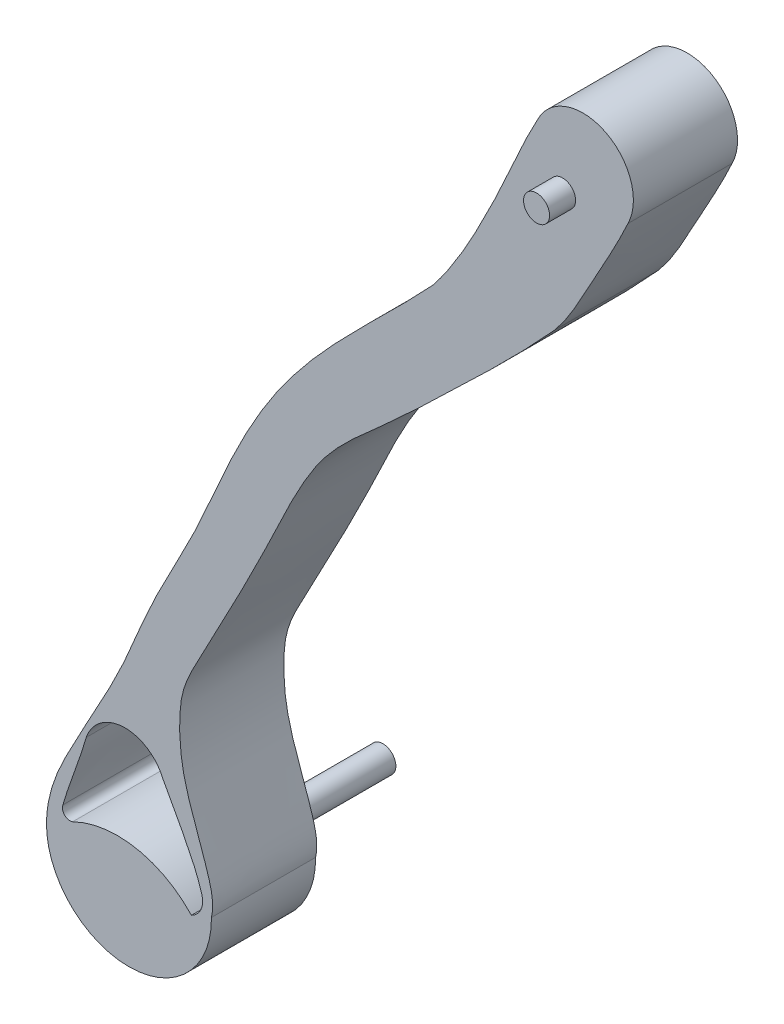
from build123d import *

# Parameters (mm, degrees)
BOSS_EXTRUDE1_DEPTH = 40
SKETCH3_R           = 5
BOSS_EXTRUDE3_DEPTH = 10
CUT_EXTRUDE1_DEPTH  = 40
BOSS_EXTRUDE6_START = -50
SKETCH3_2_R         = 5
BOSS_EXTRUDE6_DEPTH = 50
SKETCH4_R           = 5
BOSS_EXTRUDE7_DEPTH = 100


with BuildPart() as part:
    # Sketch1 → Boss-Extrude1 (new body)
    with BuildSketch(Plane.XY):
        with BuildLine():
            ThreePointArc((-128.435303347, -140.896902453), (-96.755149526, -173.125351057), (-65.074995705, -140.896902453))
            add(Edge.make_bspline(
                [(-65.074995705, -140.896902453), (-63.907652097, -135.87464552), (-66.35100912, -126.659238679), (-71.697657005, -112.128089654), (-76.334712316, -98.472209398), (-77.541709446, -84.207198732), (-76.961960819, -70.342092539), (-68.88579276, -55.69495944), (-58.213845257, -35.305524849), (-45.109839414, -10.285325139), (-33.851241856, 14.939291119), (-19.441261208, 38.761764832), (0.34611134, 54.846253057), (30.149690797, 83.353080433), (52.005250373, 104.155990976), (66.875865875, 120.550338304)],
                knots=[0, 0, 0, 0, 0.04686952, 0.090141713, 0.148581226, 0.183456914, 0.226900489, 0.278590854, 0.340349479, 0.448130788, 0.547901997, 0.604794059, 0.712230619, 0.788345355, 1, 1, 1, 1], degree=3))
            add(Edge.make_bspline(
                [(66.875865875, 120.550338304), (72.386556563, 127.19913785), (81.101735437, 144.070801532), (90.587580648, 160.476032838), (94.896483447, 169.931016127)],
                knots=[0, 0, 0, 0, 0.452321954, 1, 1, 1, 1], degree=3))
            ThreePointArc((94.896483447, 169.931016127), (86.447657386, 195.991479609), (60.387193905, 187.542653548))
            add(Edge.make_bspline(
                [(19.939027909, 111.952234191), (26.24809298, 119.800552758), (36.071780336, 136.393112866), (48.541442057, 162.180154607), (55.829036332, 179.301734236), (60.387193905, 187.542653548)],
                knots=[0, 0, 0, 0, 0.350645712, 0.671542658, 1, 1, 1, 1], degree=3))
            add(Edge.make_bspline(
                [(19.939027909, 111.952234191), (3.65232557, 94.329038748), (-20.249605672, 73.621931367), (-45.652429062, 39.041142074), (-58.842646897, 13.609703306), (-71.789487323, -18.071990564), (-87.738861669, -45.500334261), (-100.863433523, -79.921354986), (-115.452059141, -103.788445803), (-126.143907942, -125.769991297), (-128.340182149, -135.353702394), (-128.435303347, -140.896902453)],
                knots=[0, 0, 0, 0, 0.227860936, 0.297082932, 0.405625713, 0.498415505, 0.621398378, 0.705377541, 0.846798383, 0.88536092, 0.937345032, 0.937345032, 0.937345032, 0.937345032], degree=3))
        make_face()
    extrude(amount=BOSS_EXTRUDE1_DEPTH)

    # Sketch3 → Boss-Extrude3 (add)
    with BuildSketch(Plane.XY.offset(40)):
        with Locations((69.819387709, 167.582956348)):
            Circle(SKETCH3_R)
    extrude(amount=BOSS_EXTRUDE3_DEPTH)

    # Sketch2 → Cut-Extrude1 (cut)
    with BuildSketch(Plane(origin=(0, 0, 0), x_dir=(-1, 0, 0), z_dir=(0, 0, -1))):
        with BuildLine():
            ThreePointArc((68.756079477, -135.101198343), (69.135093574, -140.284053245), (72.767176325, -144.000719965))
            ThreePointArc((72.767176325, -144.000719965), (94.214636305, -132.290590151), (118.40985459, -135.71288353))
            ThreePointArc((118.40985459, -135.71288353), (121.480604985, -135.007019726), (122.117435387, -131.921213715))
            add(Edge.make_bspline(
                [(122.117435387, -131.921213715), (121.902241698, -131.121274345), (121.440830196, -129.570265663), (120.671868024, -127.192672605), (119.652569307, -124.170271778), (118.304661288, -120.363805326), (116.083389287, -114.1940152), (114.313518517, -109.046051235), (113.271974893, -105.380725172), (113.174364562, -105.029678695)],
                knots=[0.036199993, 0.036199993, 0.036199993, 0.036199993, 0.044998375, 0.052823255, 0.060648134, 0.076297892, 0.091947651, 0.123247168, 0.126550229, 0.126550229, 0.126550229, 0.126550229], degree=3))
            ThreePointArc((113.174364562, -105.029678695), (98.834885933, -94.391617828), (83.767621929, -103.971103295))
            add(Edge.make_bspline(
                [(83.767621929, -103.971103295), (83.587351822, -104.298739766), (81.914012514, -107.339065994), (79.505680761, -111.713780784), (76.624782808, -117.103856723), (74.514987608, -121.165521306), (72.523371571, -125.181904734), (70.751114993, -129.17446861), (69.536178497, -132.477867128), (68.933551478, -134.470064331), (68.756079477, -135.101198343)],
                knots=[0.787262055, 0.787262055, 0.787262055, 0.787262055, 0.790799641, 0.820108719, 0.834763258, 0.849417797, 0.864072336, 0.878726875, 0.893381414, 0.900142659, 0.900142659, 0.900142659, 0.900142659], degree=3))
        make_face()
    extrude(amount=-CUT_EXTRUDE1_DEPTH, mode=Mode.SUBTRACT)

    # Sketch3_2 → Boss-Extrude6 (add)
    with BuildSketch(Plane.XY.offset(40).offset(BOSS_EXTRUDE6_START)):
        with Locations((69.819387709, 167.582956348)):
            Circle(SKETCH3_2_R)
    extrude(amount=BOSS_EXTRUDE6_DEPTH)

    # Sketch4 → Boss-Extrude7 (add)
    with BuildSketch(Plane.XY.offset(40)):
        with Locations((-99.230093204, -155.129512749)):
            Circle(SKETCH4_R)
    extrude(amount=-BOSS_EXTRUDE7_DEPTH)


solid = part.part
